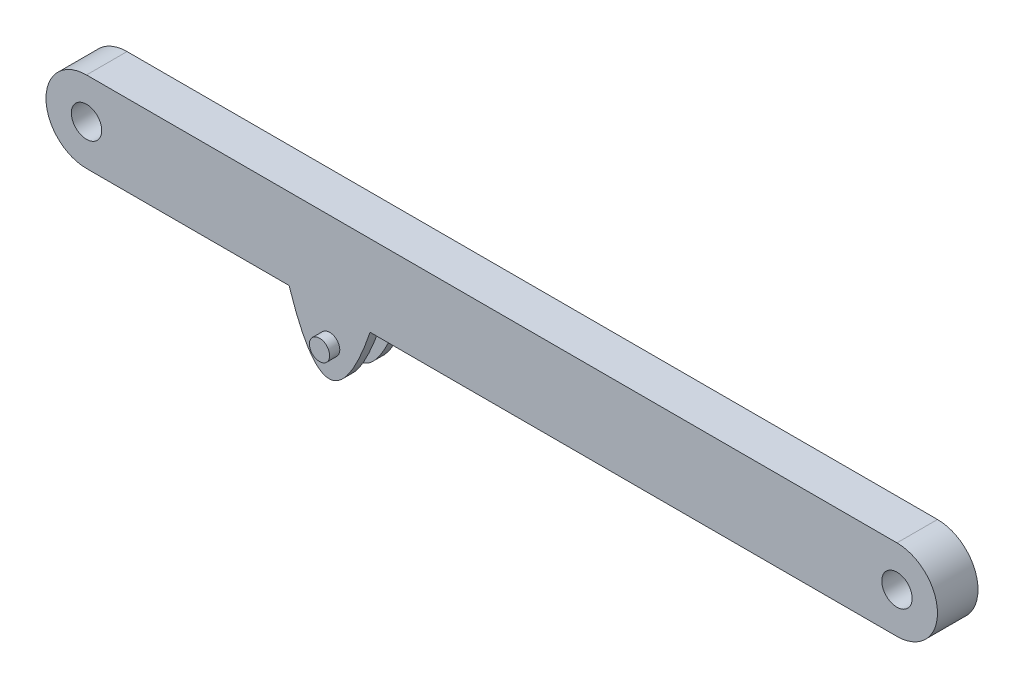
from build123d import *

# Parameters (mm, degrees)
BOSS_EXTRUDE1_DEPTH = 20
SKETCH4_R           = 7.5
CUT_EXTRUDE1_DEPTH  = 20
BOSS_EXTRUDE2_DEPTH = 5
BOSS_EXTRUDE3_START = -5
SKETCH9_R           = 5
BOSS_EXTRUDE3_DEPTH = 15


with BuildPart() as part:
    # Sketch2 → Boss-Extrude1 (new body)
    with BuildSketch(Plane.XY):
        with BuildLine():
            Line((-200, 20), (200, 20))
            ThreePointArc((200, 20), (220, 0), (200, -20))
            Line((200, -20), (-200, -20))
            ThreePointArc((-200, -20), (-220, 0), (-200, 20))
        make_face()
    extrude(amount=BOSS_EXTRUDE1_DEPTH)

    # Sketch4 → Cut-Extrude1 (cut)
    with BuildSketch(Plane.XY.offset(20)):
        with Locations((-200, 0)):
            Circle(SKETCH4_R)
        with Locations((200, 0)):
            Circle(SKETCH4_R)
    extrude(amount=-CUT_EXTRUDE1_DEPTH, mode=Mode.SUBTRACT)

    # Sketch8 → Boss-Extrude2 (add)
    with BuildSketch(Plane.XY):
        with BuildLine():
            Line((-100.037555, -20), (-60.037555, -20))
            add(Edge.make_bspline(
                [(-100.037555, -20), (-80.4932082, -80.001537629), (-60.037555, -20)],
                knots=[0, 0, 0, 1, 1, 1], degree=2))
        make_face()
    boss_extrude2 = extrude(amount=BOSS_EXTRUDE2_DEPTH)

    # Sketch9 → Boss-Extrude3 (add)
    with BuildSketch(Plane.XY.offset(BOSS_EXTRUDE3_START)):
        with Locations((-80, -35)):
            Circle(SKETCH9_R)
    boss_extrude3 = extrude(amount=BOSS_EXTRUDE3_DEPTH)

    # Mirror2: Boss-Extrude2, Boss-Extrude3 across plane
    add(boss_extrude2.mirror(Plane.XY.offset(10)))
    add(boss_extrude3.mirror(Plane.XY.offset(10)))


solid = part.part
